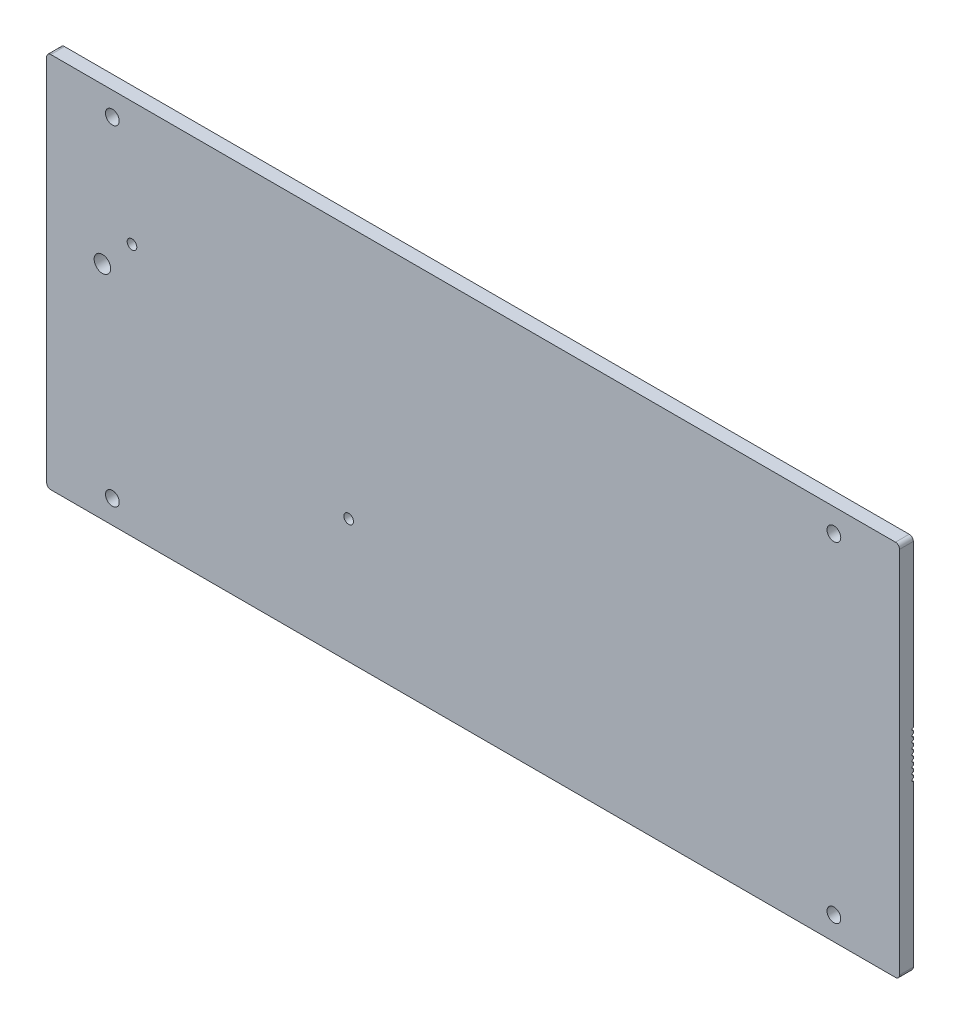
from build123d import *

# Parameters (mm, degrees)
BOSS_EXTRU_1_DEPTH           = 5
ESQUISSE2_R                  = 2.5
ENL_V_MAT_EXTRU_1_DEPTH      = 5
ESQUISSE3_R                  = 0.5
ENL_V_MAT_EXTRU_2_DEPTH      = 1
ENL_V_MAT_EXTRU_2_DEPTH_BACK = 311
ESQUISSE4_R                  = 1.75
ENL_V_MAT_EXTRU_3_DEPTH      = 5
ESQUISSE6_R                  = 3
ENL_V_MAT_EXTRU_4_DEPTH      = 5
CONG_1_R                     = 0.5


with BuildPart() as part:
    # Esquisse1 → Boss.-Extru.1 (new body)
    with BuildSketch(Plane.XY):
        with BuildLine():
            Line((-153.5, -68.5), (153.5, -68.5))
            ThreePointArc((153.5, -68.5), (154.560660172, -68.060660172), (155, -67))
            Line((155, -67), (155, 67))
            ThreePointArc((155, 67), (154.560660172, 68.060660172), (153.5, 68.5))
            Line((153.5, 68.5), (-153.5, 68.5))
            ThreePointArc((-153.5, 68.5), (-154.560660172, 68.060660172), (-155, 67))
            Line((-155, 67), (-155, -67))
            ThreePointArc((-155, -67), (-154.560660172, -68.060660172), (-153.5, -68.5))
        make_face()
    extrude(amount=BOSS_EXTRU_1_DEPTH)

    # Esquisse2 → Enlèv. mat.-Extru.1 (cut)
    with BuildSketch(Plane(origin=(0, 0, 0), x_dir=(-1, 0, 0), z_dir=(0, 0, -1))):
        with Locations((-131.119201541, -60)):
            Circle(ESQUISSE2_R)
        with Locations((-131.119201541, 60)):
            Circle(ESQUISSE2_R)
        with Locations((131.119201541, 60)):
            Circle(ESQUISSE2_R)
        with Locations((131.119201541, -60)):
            Circle(ESQUISSE2_R)
    extrude(amount=-ENL_V_MAT_EXTRU_1_DEPTH, mode=Mode.SUBTRACT)

    # Esquisse3 → Enlèv. mat.-Extru.2 (cut, two sides)
    with BuildSketch(Plane(origin=(155, 0, 0), x_dir=(0, 0, -1), z_dir=(1, 0, 0))) as enl_v_mat_extru_2_sk:
        Circle(ESQUISSE3_R)
        with Locations((0, 2)):
            Circle(ESQUISSE3_R)
        with Locations((0, 4)):
            Circle(ESQUISSE3_R)
        with Locations((0, 6)):
            Circle(ESQUISSE3_R)
        with Locations((0, 8)):
            Circle(ESQUISSE3_R)
        with Locations((0, -2)):
            Circle(ESQUISSE3_R)
        with Locations((0, -4)):
            Circle(ESQUISSE3_R)
        with Locations((0, -6)):
            Circle(ESQUISSE3_R)
        with Locations((0, -8)):
            Circle(ESQUISSE3_R)
    extrude(amount=ENL_V_MAT_EXTRU_2_DEPTH, mode=Mode.SUBTRACT)
    extrude(enl_v_mat_extru_2_sk.sketch, amount=-ENL_V_MAT_EXTRU_2_DEPTH_BACK, mode=Mode.SUBTRACT)

    # Esquisse4 → Enlèv. mat.-Extru.3 (cut)
    with BuildSketch(Plane(origin=(0, 0, 0), x_dir=(-1, 0, 0), z_dir=(0, 0, -1))):
        with Locations((45.235873588, -23.5)):
            Circle(ESQUISSE4_R)
        with Locations((123.985873588, 23.5)):
            Circle(ESQUISSE4_R)
    extrude(amount=-ENL_V_MAT_EXTRU_3_DEPTH, mode=Mode.SUBTRACT)

    # Esquisse6 → Enlèv. mat.-Extru.4 (cut)
    with BuildSketch(Plane(origin=(0, 0, 0), x_dir=(-1, 0, 0), z_dir=(0, 0, -1))):
        with Locations((134.746454325, 11.977670931)):
            Circle(ESQUISSE6_R)
    extrude(amount=-ENL_V_MAT_EXTRU_4_DEPTH, mode=Mode.SUBTRACT)

    # Congé1
    cong_1_edges = [part.edges().sort_by_distance(p)[0] for p in [
        (-131.746454325, 11.977670931, 0),
    ]]
    fillet(cong_1_edges, radius=CONG_1_R)


solid = part.part
